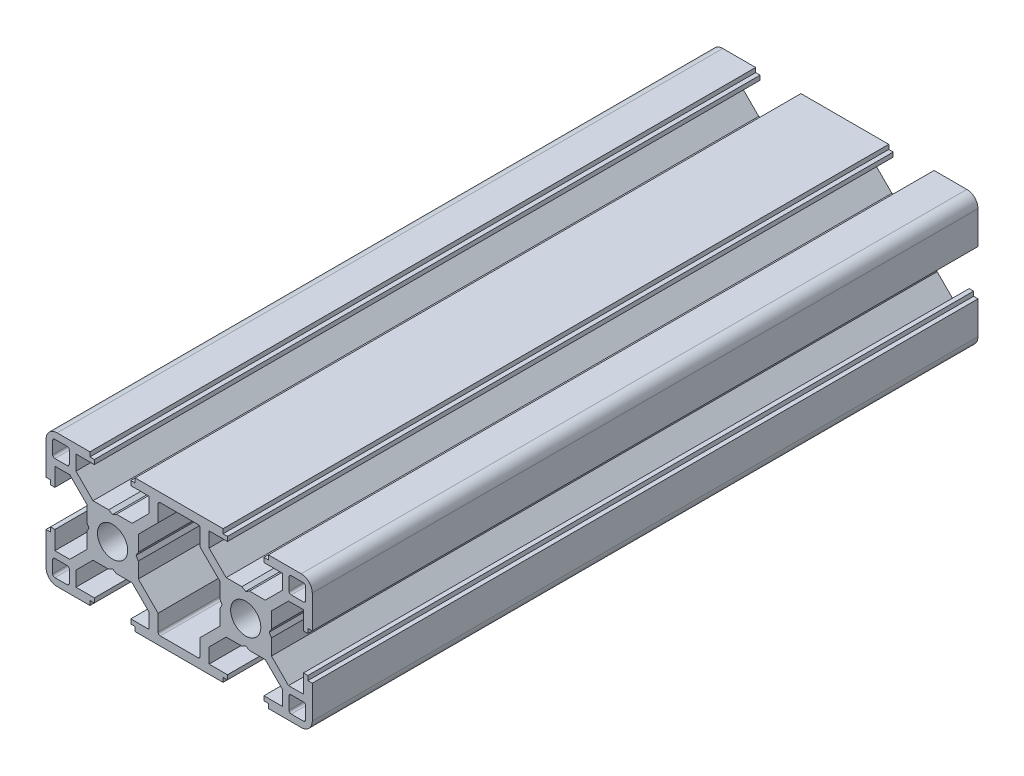
from build123d import *

# Parameters (mm, degrees)
ESQUISSE1_R      = 3.4
EXTRUSION1_DEPTH = 150


with BuildPart() as part:
    # Esquisse1 → Extrusion1 (new body)
    with BuildSketch(Plane.XY):
        with BuildLine():
            Line((16.03204155, 18.693478261), (15.03204155, 18.693478261))
            Line((15.03204155, 18.693478261), (15.03204155, 19.693478261))
            Line((15.03204155, 19.693478261), (-4.76795845, 19.693478261))
            Line((-4.76795845, 19.693478261), (-4.76795845, 18.693478261))
            Line((-4.76795845, 18.693478261), (-5.76795845, 18.693478261))
            Line((-5.76795845, 18.693478261), (-5.76795845, 17.693478261))
            Line((-5.76795845, 17.693478261), (-1.61795845, 17.693478261))
            Line((-1.61795845, 17.693478261), (-1.61795845, 14.33992487))
            Line((-1.61795845, 14.33992487), (-5.464405059, 10.493478261))
            Line((-5.464405059, 10.493478261), (-9.001933046, 10.493478261))
            Line((-9.001933046, 10.493478261), (-9.86795845, 9.993478261))
            Line((-9.86795845, 9.993478261), (-10.733983853, 10.493478261))
            Line((-10.733983853, 10.493478261), (-14.27151184, 10.493478261))
            Line((-14.27151184, 10.493478261), (-18.11795845, 14.33992487))
            Line((-18.11795845, 14.33992487), (-18.11795845, 17.693478261))
            Line((-18.11795845, 17.693478261), (-13.96795845, 17.693478261))
            Line((-13.96795845, 17.693478261), (-13.96795845, 18.693478261))
            Line((-13.96795845, 18.693478261), (-14.96795845, 18.693478261))
            Line((-14.96795845, 18.693478261), (-14.96795845, 19.693478261))
            Line((-14.96795845, 19.693478261), (-22.36795845, 19.693478261))
            ThreePointArc((-22.36795845, 19.693478261), (-24.135725403, 18.961245214), (-24.86795845, 17.193478261))
            Line((-24.86795845, 17.193478261), (-24.86795845, 9.793478261))
            Line((-24.86795845, 9.793478261), (-23.86795845, 9.793478261))
            Line((-23.86795845, 9.793478261), (-23.86795845, 8.793478261))
            Line((-23.86795845, 8.793478261), (-22.86795845, 8.793478261))
            Line((-22.86795845, 8.793478261), (-22.86795845, 12.943478261))
            Line((-22.86795845, 12.943478261), (-19.514405059, 12.943478261))
            Line((-19.514405059, 12.943478261), (-15.66795845, 9.097031651))
            Line((-15.66795845, 9.097031651), (-15.66795845, 5.559503665))
            Line((-15.66795845, 5.559503665), (-15.16795845, 4.693478261))
            Line((-15.16795845, 4.693478261), (-15.66795845, 3.827452857))
            Line((-15.66795845, 3.827452857), (-15.66795845, 0.28992487))
            Line((-15.66795845, 0.28992487), (-19.514405059, -3.556521739))
            Line((-19.514405059, -3.556521739), (-22.86795845, -3.556521739))
            Line((-22.86795845, -3.556521739), (-22.86795845, 0.593478261))
            Line((-22.86795845, 0.593478261), (-23.86795845, 0.593478261))
            Line((-23.86795845, 0.593478261), (-23.86795845, -0.406521739))
            Line((-23.86795845, -0.406521739), (-24.86795845, -0.406521739))
            Line((-24.86795845, -0.406521739), (-24.86795845, -7.806521739))
            ThreePointArc((-24.86795845, -7.806521739), (-24.135725403, -9.574288692), (-22.36795845, -10.306521739))
            Line((-22.36795845, -10.306521739), (-14.96795845, -10.306521739))
            Line((-14.96795845, -10.306521739), (-14.96795845, -9.306521739))
            Line((-14.96795845, -9.306521739), (-13.96795845, -9.306521739))
            Line((-13.96795845, -9.306521739), (-13.96795845, -8.306521739))
            Line((-13.96795845, -8.306521739), (-18.11795845, -8.306521739))
            Line((-18.11795845, -8.306521739), (-18.11795845, -4.952968349))
            Line((-18.11795845, -4.952968349), (-14.27151184, -1.106521739))
            Line((-14.27151184, -1.106521739), (-10.733983853, -1.106521739))
            Line((-10.733983853, -1.106521739), (-9.86795845, -0.606521739))
            Line((-9.86795845, -0.606521739), (-9.001933046, -1.106521739))
            Line((-9.001933046, -1.106521739), (-5.464405059, -1.106521739))
            Line((-5.464405059, -1.106521739), (-1.61795845, -4.952968349))
            Line((-1.61795845, -4.952968349), (-1.61795845, -8.306521739))
            Line((-1.61795845, -8.306521739), (-5.76795845, -8.306521739))
            Line((-5.76795845, -8.306521739), (-5.76795845, -9.306521739))
            Line((-5.76795845, -9.306521739), (-4.76795845, -9.306521739))
            Line((-4.76795845, -9.306521739), (-4.76795845, -10.306521739))
            Line((-4.76795845, -10.306521739), (15.03204155, -10.306521739))
            Line((15.03204155, -10.306521739), (15.03204155, -9.306521739))
            Line((15.03204155, -9.306521739), (16.03204155, -9.306521739))
            Line((16.03204155, -9.306521739), (16.03204155, -8.306521739))
            Line((16.03204155, -8.306521739), (11.88204155, -8.306521739))
            Line((11.88204155, -8.306521739), (11.88204155, -4.952968349))
            Line((11.88204155, -4.952968349), (15.72848816, -1.106521739))
            Line((15.72848816, -1.106521739), (19.266016147, -1.106521739))
            Line((19.266016147, -1.106521739), (20.13204155, -0.606521739))
            Line((20.13204155, -0.606521739), (20.998066954, -1.106521739))
            Line((20.998066954, -1.106521739), (24.535594941, -1.106521739))
            Line((24.535594941, -1.106521739), (28.38204155, -4.952968349))
            Line((28.38204155, -4.952968349), (28.38204155, -8.306521739))
            Line((28.38204155, -8.306521739), (24.23204155, -8.306521739))
            Line((24.23204155, -8.306521739), (24.23204155, -9.306521739))
            Line((24.23204155, -9.306521739), (25.23204155, -9.306521739))
            Line((25.23204155, -9.306521739), (25.23204155, -10.306521739))
            Line((25.23204155, -10.306521739), (32.63204155, -10.306521739))
            ThreePointArc((32.63204155, -10.306521739), (34.399808503, -9.574288692), (35.13204155, -7.806521739))
            Line((35.13204155, -7.806521739), (35.13204155, -0.406521739))
            Line((35.13204155, -0.406521739), (34.13204155, -0.406521739))
            Line((34.13204155, -0.406521739), (34.13204155, 0.593478261))
            Line((34.13204155, 0.593478261), (33.13204155, 0.593478261))
            Line((33.13204155, 0.593478261), (33.13204155, -3.556521739))
            Line((33.13204155, -3.556521739), (29.77848816, -3.556521739))
            Line((29.77848816, -3.556521739), (25.93204155, 0.28992487))
            Line((25.93204155, 0.28992487), (25.93204155, 3.827452857))
            Line((25.93204155, 3.827452857), (25.43204155, 4.693478261))
            Line((25.43204155, 4.693478261), (25.93204155, 5.559503665))
            Line((25.93204155, 5.559503665), (25.93204155, 9.097031651))
            Line((25.93204155, 9.097031651), (29.77848816, 12.943478261))
            Line((29.77848816, 12.943478261), (33.13204155, 12.943478261))
            Line((33.13204155, 12.943478261), (33.13204155, 8.793478261))
            Line((33.13204155, 8.793478261), (34.13204155, 8.793478261))
            Line((34.13204155, 8.793478261), (34.13204155, 9.793478261))
            Line((34.13204155, 9.793478261), (35.13204155, 9.793478261))
            Line((35.13204155, 9.793478261), (35.13204155, 17.193478261))
            ThreePointArc((35.13204155, 17.193478261), (34.399808503, 18.961245214), (32.63204155, 19.693478261))
            Line((32.63204155, 19.693478261), (25.23204155, 19.693478261))
            Line((25.23204155, 19.693478261), (25.23204155, 18.693478261))
            Line((25.23204155, 18.693478261), (24.23204155, 18.693478261))
            Line((24.23204155, 18.693478261), (24.23204155, 17.693478261))
            Line((24.23204155, 17.693478261), (28.38204155, 17.693478261))
            Line((28.38204155, 17.693478261), (28.38204155, 14.33992487))
            Line((28.38204155, 14.33992487), (24.535594941, 10.493478261))
            Line((24.535594941, 10.493478261), (20.998066954, 10.493478261))
            Line((20.998066954, 10.493478261), (20.13204155, 9.993478261))
            Line((20.13204155, 9.993478261), (19.266016147, 10.493478261))
            Line((19.266016147, 10.493478261), (15.72848816, 10.493478261))
            Line((15.72848816, 10.493478261), (11.88204155, 14.33992487))
            Line((11.88204155, 14.33992487), (11.88204155, 17.693478261))
            Line((11.88204155, 17.693478261), (16.03204155, 17.693478261))
            Line((16.03204155, 17.693478261), (16.03204155, 18.693478261))
        make_face()
        with Locations((-9.86795845, 4.693478261)):
            Circle(ESQUISSE1_R, mode=Mode.SUBTRACT)
        with Locations((20.13204155, 4.693478261)):
            Circle(ESQUISSE1_R, mode=Mode.SUBTRACT)
        with BuildLine():
            Line((-23.36795845, 14.943478261), (-23.36795845, 17.693478261))
            ThreePointArc((-23.36795845, 17.693478261), (-23.22151184, 18.047031651), (-22.86795845, 18.193478261))
            Line((-22.86795845, 18.193478261), (-20.11795845, 18.193478261))
            ThreePointArc((-20.11795845, 18.193478261), (-19.764405059, 18.047031651), (-19.61795845, 17.693478261))
            Line((-19.61795845, 17.693478261), (-19.61795845, 14.943478261))
            ThreePointArc((-19.61795845, 14.943478261), (-19.764405059, 14.58992487), (-20.11795845, 14.443478261))
            Line((-20.11795845, 14.443478261), (-22.86795845, 14.443478261))
            ThreePointArc((-22.86795845, 14.443478261), (-23.22151184, 14.58992487), (-23.36795845, 14.943478261))
        make_face(mode=Mode.SUBTRACT)
        with BuildLine():
            Line((-19.61795845, -5.556521739), (-19.61795845, -8.306521739))
            ThreePointArc((-19.61795845, -8.306521739), (-19.764405059, -8.66007513), (-20.11795845, -8.806521739))
            Line((-20.11795845, -8.806521739), (-22.86795845, -8.806521739))
            ThreePointArc((-22.86795845, -8.806521739), (-23.22151184, -8.66007513), (-23.36795845, -8.306521739))
            Line((-23.36795845, -8.306521739), (-23.36795845, -5.556521739))
            ThreePointArc((-23.36795845, -5.556521739), (-23.22151184, -5.202968349), (-22.86795845, -5.056521739))
            Line((-22.86795845, -5.056521739), (-20.11795845, -5.056521739))
            ThreePointArc((-20.11795845, -5.056521739), (-19.764405059, -5.202968349), (-19.61795845, -5.556521739))
        make_face(mode=Mode.SUBTRACT)
        with BuildLine():
            Line((14.33204155, 0.325458776), (9.88204155, -4.124541224))
            Line((9.88204155, -4.124541224), (9.88204155, -7.806521739))
            ThreePointArc((9.88204155, -7.806521739), (9.735594941, -8.16007513), (9.38204155, -8.306521739))
            Line((9.38204155, -8.306521739), (0.88204155, -8.306521739))
            ThreePointArc((0.88204155, -8.306521739), (0.52848816, -8.16007513), (0.38204155, -7.806521739))
            Line((0.38204155, -7.806521739), (0.38204155, -4.124541224))
            Line((0.38204155, -4.124541224), (-4.06795845, 0.325458776))
            Line((-4.06795845, 0.325458776), (-4.06795845, 3.827452857))
            Line((-4.06795845, 3.827452857), (-4.56795845, 4.693478261))
            Line((-4.56795845, 4.693478261), (-4.06795845, 5.559503665))
            Line((-4.06795845, 5.559503665), (-4.06795845, 9.061497746))
            Line((-4.06795845, 9.061497746), (0.38204155, 13.511497746))
            Line((0.38204155, 13.511497746), (0.38204155, 17.193478261))
            ThreePointArc((0.38204155, 17.193478261), (0.52848816, 17.547031651), (0.88204155, 17.693478261))
            Line((0.88204155, 17.693478261), (9.38204155, 17.693478261))
            ThreePointArc((9.38204155, 17.693478261), (9.735594941, 17.547031651), (9.88204155, 17.193478261))
            Line((9.88204155, 17.193478261), (9.88204155, 13.511497746))
            Line((9.88204155, 13.511497746), (14.33204155, 9.061497746))
            Line((14.33204155, 9.061497746), (14.33204155, 5.559503665))
            Line((14.33204155, 5.559503665), (14.83204155, 4.693478261))
            Line((14.83204155, 4.693478261), (14.33204155, 3.827452857))
            Line((14.33204155, 3.827452857), (14.33204155, 0.325458776))
        make_face(mode=Mode.SUBTRACT)
        with BuildLine():
            Line((29.88204155, 14.943478261), (29.88204155, 17.693478261))
            ThreePointArc((29.88204155, 17.693478261), (30.02848816, 18.047031651), (30.38204155, 18.193478261))
            Line((30.38204155, 18.193478261), (33.13204155, 18.193478261))
            ThreePointArc((33.13204155, 18.193478261), (33.485594941, 18.047031651), (33.63204155, 17.693478261))
            Line((33.63204155, 17.693478261), (33.63204155, 14.943478261))
            ThreePointArc((33.63204155, 14.943478261), (33.485594941, 14.58992487), (33.13204155, 14.443478261))
            Line((33.13204155, 14.443478261), (30.38204155, 14.443478261))
            ThreePointArc((30.38204155, 14.443478261), (30.02848816, 14.58992487), (29.88204155, 14.943478261))
        make_face(mode=Mode.SUBTRACT)
        with BuildLine():
            Line((29.88204155, -8.306521739), (29.88204155, -5.556521739))
            ThreePointArc((29.88204155, -5.556521739), (30.02848816, -5.202968349), (30.38204155, -5.056521739))
            Line((30.38204155, -5.056521739), (33.13204155, -5.056521739))
            ThreePointArc((33.13204155, -5.056521739), (33.485594941, -5.202968349), (33.63204155, -5.556521739))
            Line((33.63204155, -5.556521739), (33.63204155, -8.306521739))
            ThreePointArc((33.63204155, -8.306521739), (33.485594941, -8.66007513), (33.13204155, -8.806521739))
            Line((33.13204155, -8.806521739), (30.38204155, -8.806521739))
            ThreePointArc((30.38204155, -8.806521739), (30.02848816, -8.66007513), (29.88204155, -8.306521739))
        make_face(mode=Mode.SUBTRACT)
    extrude(amount=EXTRUSION1_DEPTH)


solid = part.part
